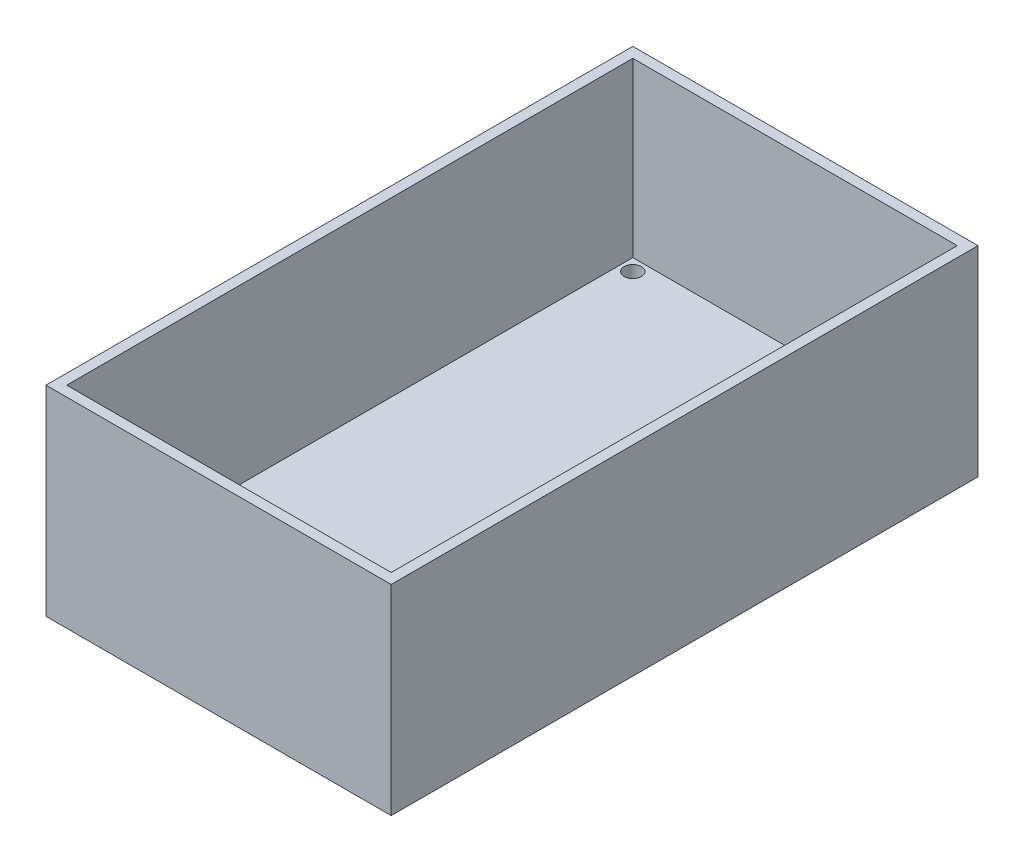
from build123d import *

# Parameters (mm, degrees)
SKETCH1_W           = 50
SKETCH1_H           = 85
SKETCH1_R           = 1.25
BOSS_EXTRUDE3_DEPTH = 4
SKETCH2_W           = 50
SKETCH2_H           = 85
SKETCH2_W_2         = 47
SKETCH2_H_2         = 82
BOSS_EXTRUDE4_DEPTH = 25


with BuildPart() as part:
    # Sketch1 → Boss-Extrude3 (new body)
    with BuildSketch(Plane(origin=(0, 0, 0), x_dir=(1, 0, 0), z_dir=(0, 1, 0))):
        with Locations((23, 40.5)):
            Rectangle(SKETCH1_W, SKETCH1_H)
        with Locations((1.25, 79.75)):
            Circle(SKETCH1_R, mode=Mode.SUBTRACT)
        with Locations((44.75, 79.75)):
            Circle(SKETCH1_R, mode=Mode.SUBTRACT)
        with Locations((44.75, 1.25)):
            Circle(SKETCH1_R, mode=Mode.SUBTRACT)
        with Locations((1.25, 1.25)):
            Circle(SKETCH1_R, mode=Mode.SUBTRACT)
    extrude(amount=BOSS_EXTRUDE3_DEPTH)

    # Sketch2 → Boss-Extrude4 (add)
    with BuildSketch(Plane(origin=(0, 4, 0), x_dir=(1, 0, 0), z_dir=(0, 1, 0))):
        with Locations((23, 40.5)):
            Rectangle(SKETCH2_W, SKETCH2_H)
        with Locations((23, 40.5)):
            Rectangle(SKETCH2_W_2, SKETCH2_H_2, mode=Mode.SUBTRACT)
    extrude(amount=BOSS_EXTRUDE4_DEPTH)


solid = part.part
